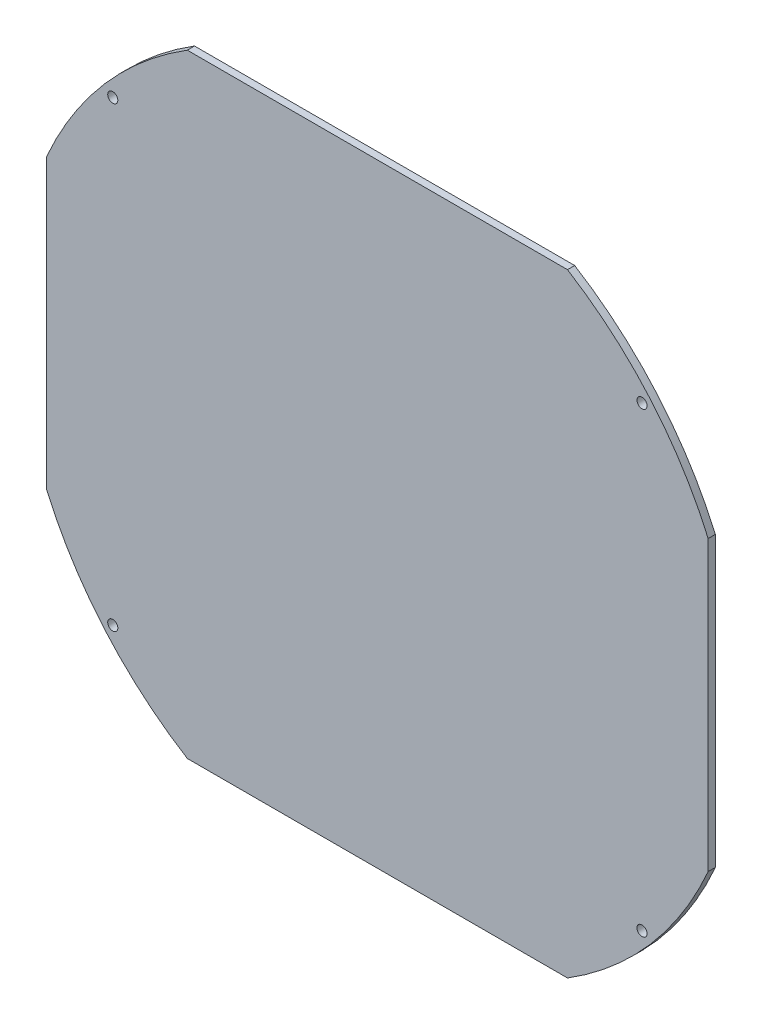
from build123d import *

# Parameters (mm, degrees)
BOSS_EXTRUDE1_DEPTH = 3
SKETCH3_R           = 2.1
CUT_EXTRUDE1_DEPTH  = 4


with BuildPart() as part:
    # Sketch1 → Boss-Extrude1 (new body)
    with BuildSketch(Plane.XY):
        with BuildLine():
            Line((-79.017403146, -127.5), (79.017403146, -127.5))
            ThreePointArc((79.017403146, -127.5), (113.405327129, -98.179589421), (137.5, -59.947894041))
            Line((137.5, -59.947894041), (137.5, 59.947894041))
            ThreePointArc((137.5, 59.947894041), (113.405327129, 98.179589421), (79.017403146, 127.5))
            Line((79.017403146, 127.5), (-79.017403146, 127.5))
            ThreePointArc((-79.017403146, 127.5), (-113.405327129, 98.179589421), (-137.5, 59.947894041))
            Line((-137.5, 59.947894041), (-137.5, -59.947894041))
            ThreePointArc((-137.5, -59.947894041), (-113.405327129, -98.179589421), (-79.017403146, -127.5))
        make_face()
    extrude(amount=BOSS_EXTRUDE1_DEPTH)

    # Sketch3 → Cut-Extrude1 (cut, through all)
    with BuildSketch(Plane.XY.offset(3)):
        with Locations((-110, 95)):
            Circle(SKETCH3_R)
        with Locations((110, 95)):
            Circle(SKETCH3_R)
        with Locations((110, -95)):
            Circle(SKETCH3_R)
        with Locations((-110, -95)):
            Circle(SKETCH3_R)
    extrude(amount=-CUT_EXTRUDE1_DEPTH, mode=Mode.SUBTRACT)


solid = part.part
